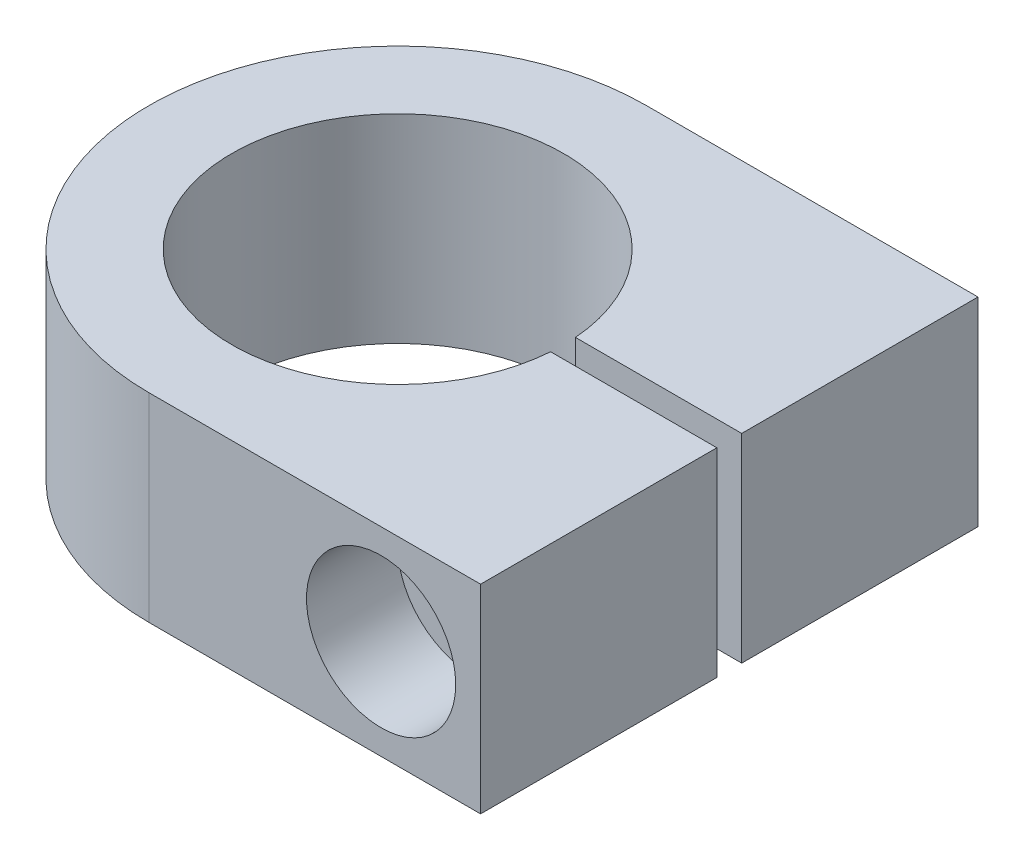
from build123d import *

# Parameters (mm, degrees)
P_IDAT_VYSUNUT_M1_DEPTH  = 24
ODEBRAT_VYSUNUT_M1_REACH = 62
SKICA2_R                 = 5.5
SKICA3_R                 = 9
ODEBRAT_VYSUNUT_M2_DEPTH = 11
M10_Z_VIT1_D             = 8.5
M10_Z_VIT1_DEPTH         = 28.5


with BuildPart() as part:
    # Skica1 → Přidat vysunutím1 (new body)
    with BuildSketch(Plane(origin=(0, 0, 0), x_dir=(1, 0, 0), z_dir=(0, 1, 0))):
        with BuildLine():
            Line((0, 0), (0, 28.5))
            Line((0, 28.5), (-20.056329325, 28.5))
            ThreePointArc((-20.056329325, 28.5), (-60, 30), (-20.056329325, 31.5))
            Line((-20.056329325, 31.5), (0, 31.5))
            Line((0, 31.5), (0, 60))
            Line((0, 60), (-40, 60))
            ThreePointArc((-40, 60), (-70, 30), (-40, 0))
            Line((-40, 0), (0, 0))
        make_face()
    extrude(amount=P_IDAT_VYSUNUT_M1_DEPTH)

    # Skica2 → Odebrat vysunutím1 (cut, up to next)
    with BuildSketch(Plane.XY, mode=Mode.PRIVATE) as odebrat_vysunut_m1_sk1:
        with Locations((-12, 12)):
            Circle(SKICA2_R)
    odebrat_vysunut_m1_tool1 = extrude(odebrat_vysunut_m1_sk1.sketch, amount=-ODEBRAT_VYSUNUT_M1_REACH, mode=Mode.PRIVATE) & part.part
    add(odebrat_vysunut_m1_tool1.solids().sort_by_distance((-12, 12, 0))[0], mode=Mode.SUBTRACT)

    # Skica3 → Odebrat vysunutím2 (cut)
    with BuildSketch(Plane.XY):
        with Locations((-12, 12)):
            Circle(SKICA3_R)
    extrude(amount=-ODEBRAT_VYSUNUT_M2_DEPTH, mode=Mode.SUBTRACT)

    # M10 závit1
    with Locations(Plane(origin=(0, 0, -60), x_dir=(-1, 0, 0), z_dir=(0, 0, -1))):
        with Locations((12, 12)):
            Hole(M10_Z_VIT1_D / 2, depth=M10_Z_VIT1_DEPTH)


solid = part.part
